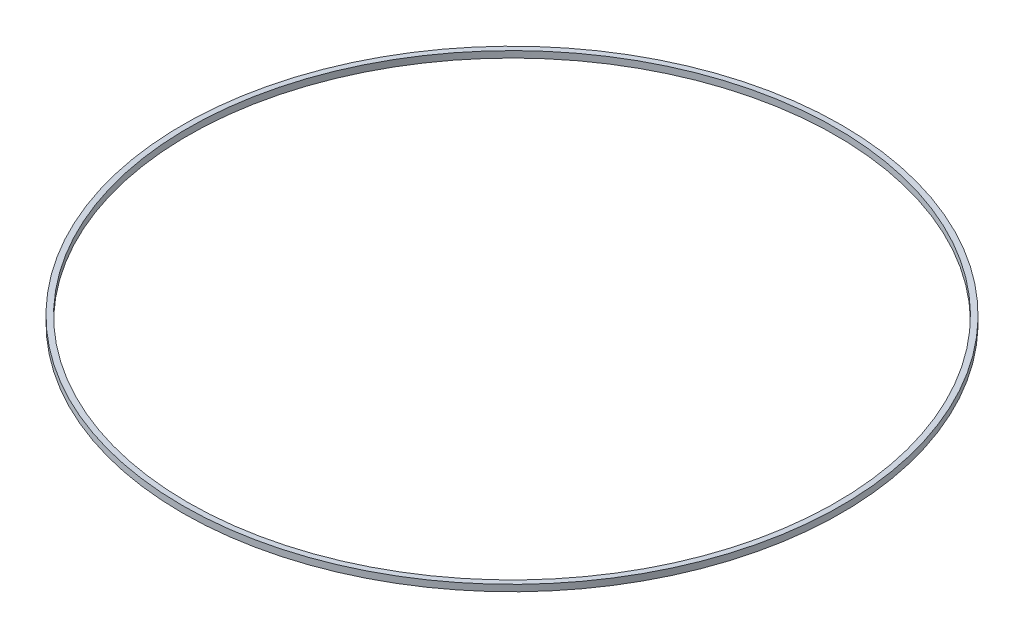
from build123d import *

# Parameters (mm, degrees)
SKETCH2_R           = 153
SKETCH2_R_2         = 150.5
BOSS_EXTRUDE1_DEPTH = 3


with BuildPart() as part:
    # Sketch2 → Boss-Extrude1 (new body)
    with BuildSketch(Plane(origin=(0, 0, 0), x_dir=(1, 0, 0), z_dir=(0, 1, 0))):
        Circle(SKETCH2_R)
        Circle(SKETCH2_R_2, mode=Mode.SUBTRACT)
    extrude(amount=BOSS_EXTRUDE1_DEPTH)


solid = part.part
